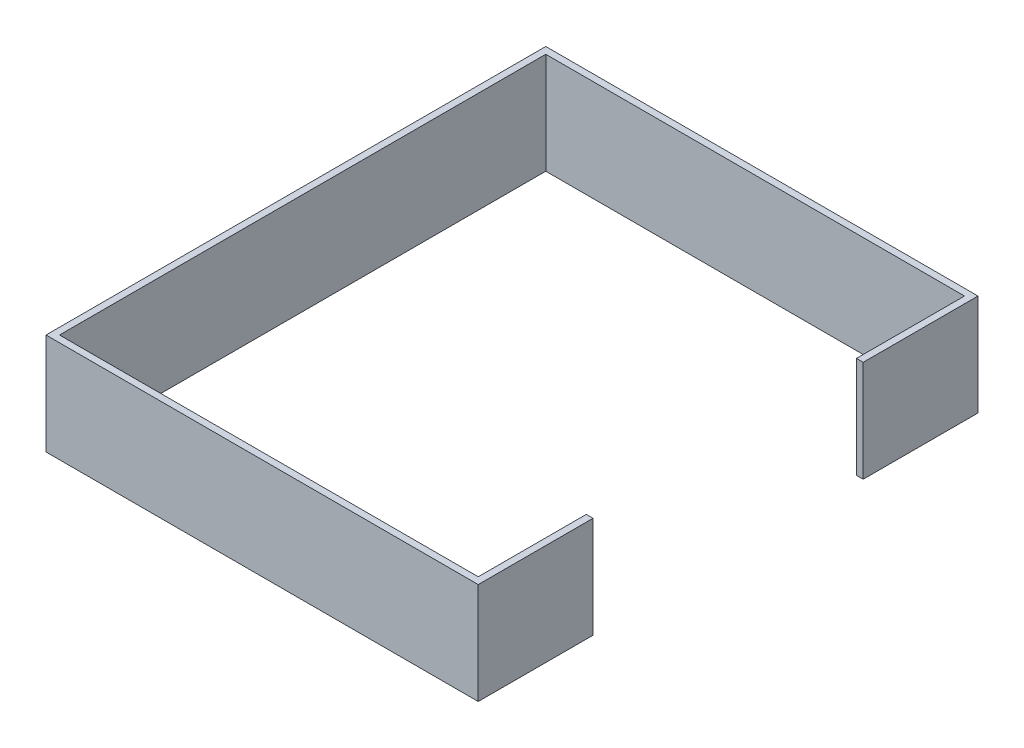
from build123d import *

# Parameters (mm, degrees)
SKETCH1_W                = 740
SKETCH1_H                = 150
BOSS_EXTRUDE1_DEPTH      = 441.94307
BOSS_EXTRUDE1_DEPTH_BACK = 198.05693
SKETCH2_W                = 620
SKETCH2_H                = 720
CUT_EXTRUDE1_DEPTH       = 150
CUT_EXTRUDE2_DEPTH       = 630


with BuildPart() as part:
    # Sketch1 → Boss-Extrude1 (new body, two sides)
    with BuildSketch(Plane(origin=(0, 0, 0), x_dir=(0, 0, -1), z_dir=(1, 0, 0))) as boss_extrude1_sk:
        with Locations((133.994417004, 1223.59608297)):
            Rectangle(SKETCH1_W, SKETCH1_H)
    extrude(amount=BOSS_EXTRUDE1_DEPTH)
    extrude(boss_extrude1_sk.sketch, amount=-BOSS_EXTRUDE1_DEPTH_BACK)

    # Sketch2 → Cut-Extrude1 (cut)
    with BuildSketch(Plane(origin=(0, 1298.59608297, 0), x_dir=(1, 0, 0), z_dir=(0, 1, 0))):
        with Locations((121.943070464, 133.994417004)):
            Rectangle(SKETCH2_W, SKETCH2_H)
    extrude(amount=-CUT_EXTRUDE1_DEPTH, mode=Mode.SUBTRACT)

    # Sketch3 → Cut-Extrude2 (cut)
    with BuildSketch(Plane(origin=(441.943070464, 0, 0), x_dir=(0, 0, -1), z_dir=(1, 0, 0))):
        Polygon((133.994417004, 1148.59608297), (333.994417004, 1148.59608297), (333.994417004, 1298.59608297), (-66.005582996, 1298.59608297), (-66.005582996, 1148.59608297), align=None)
    extrude(amount=-CUT_EXTRUDE2_DEPTH, mode=Mode.SUBTRACT)


solid = part.part
